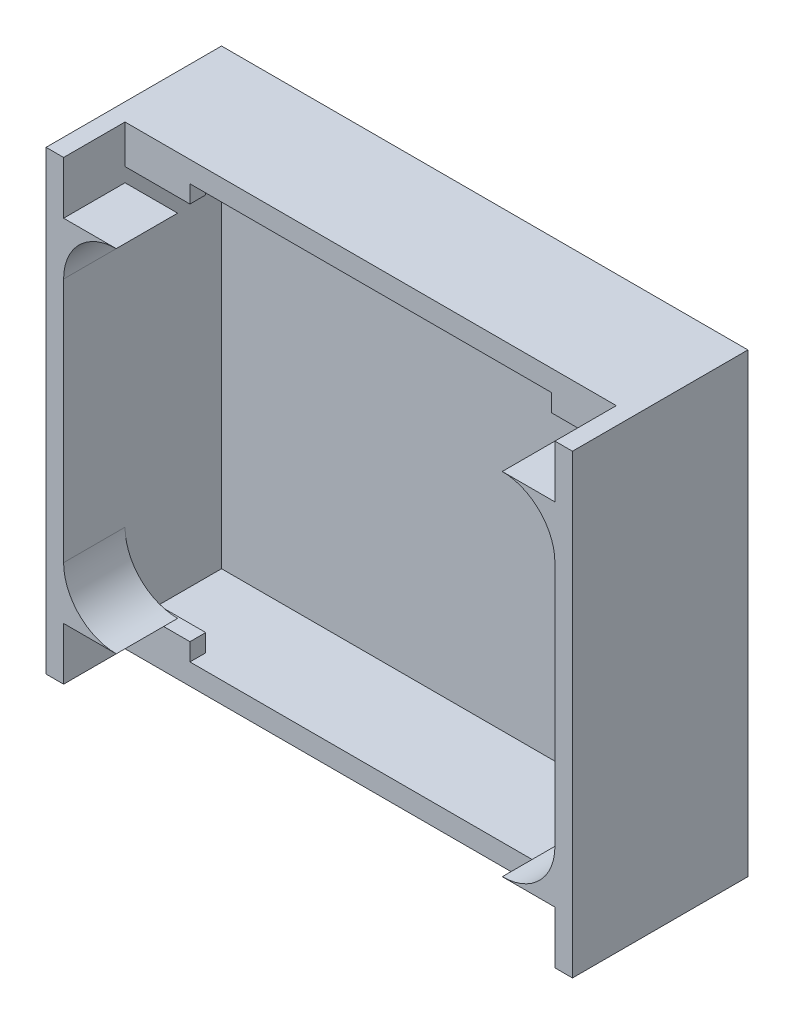
from build123d import *

# Parameters (mm, degrees)
SKETCH1_W           = 30
SKETCH1_H           = 26
BOSS_EXTRUDE1_DEPTH = 10
CUT_EXTRUDE2_DEPTH  = 3.5
SKETCH3_W           = 3
SKETCH3_H           = 3
CUT_EXTRUDE3_DEPTH  = 3.5
SKETCH4_W           = 28
SKETCH4_H           = 23.6
CUT_EXTRUDE4_DEPTH  = 5.5
SKETCH5_W           = 3.7
SKETCH5_H           = 0.9
BOSS_EXTRUDE2_DEPTH = 1
SKETCH6_W           = 3.7
SKETCH6_H           = 0.9
BOSS_EXTRUDE3_DEPTH = 1


with BuildPart() as part:
    # Sketch1 → Boss-Extrude1 (new body)
    with BuildSketch(Plane.XY):
        with Locations((0.224911006, 2.218978102)):
            Rectangle(SKETCH1_W, SKETCH1_H)
    extrude(amount=BOSS_EXTRUDE1_DEPTH)

    # Sketch2 → Cut-Extrude2 (cut)
    with BuildSketch(Plane.XY.offset(10)):
        with BuildLine():
            Line((-13.775088994, 9.218978102), (-13.775088994, -4.781021898))
            ThreePointArc((-13.775088994, -4.781021898), (-12.896409337, -6.902342241), (-10.775088994, -7.781021898))
            Line((-10.775088994, -7.781021898), (-10.775088994, -10.781021898))
            Line((-10.775088994, -10.781021898), (11.224911006, -10.781021898))
            Line((11.224911006, -10.781021898), (11.224911006, -7.781021898))
            ThreePointArc((11.224911006, -7.781021898), (13.34623135, -6.902342241), (14.224911006, -4.781021898))
            Line((14.224911006, -4.781021898), (14.224911006, 9.218978102))
            ThreePointArc((14.224911006, 9.218978102), (13.34623135, 11.340298446), (11.224911006, 12.218978102))
            Line((11.224911006, 12.218978102), (11.224911006, 15.218978102))
            Line((11.224911006, 15.218978102), (-10.775088994, 15.218978102))
            Line((-10.775088994, 15.218978102), (-10.775088994, 12.218978102))
            ThreePointArc((-10.775088994, 12.218978102), (-12.896409337, 11.340298446), (-13.775088994, 9.218978102))
        make_face()
    extrude(amount=-CUT_EXTRUDE2_DEPTH, mode=Mode.SUBTRACT)

    # Sketch3 → Cut-Extrude3 (cut)
    with BuildSketch(Plane.XY.offset(10)):
        with Locations((-12.275088994, 13.718978102)):
            Rectangle(SKETCH3_W, SKETCH3_H)
        with Locations((12.724911006, -9.281021898)):
            Rectangle(SKETCH3_W, SKETCH3_H)
        with Locations((-12.275088994, -9.281021898)):
            Rectangle(SKETCH3_W, SKETCH3_H)
        with Locations((12.724911006, 13.718978102)):
            Rectangle(SKETCH3_W, SKETCH3_H)
    extrude(amount=-CUT_EXTRUDE3_DEPTH, mode=Mode.SUBTRACT)

    # Sketch4 → Cut-Extrude4 (cut)
    with BuildSketch(Plane.XY.offset(6.5)):
        with Locations((0.224911006, 2.218978102)):
            Rectangle(SKETCH4_W, SKETCH4_H)
    extrude(amount=-CUT_EXTRUDE4_DEPTH, mode=Mode.SUBTRACT)

    # Sketch5 → Boss-Extrude2 (add)
    with BuildSketch(Plane(origin=(0, 14.018978102, 0), x_dir=(-1, 0, 0), z_dir=(0, -1, 0))):
        with Locations((11.925088994, -6.05)):
            Rectangle(SKETCH5_W, SKETCH5_H)
        with Locations((-12.374911006, -6.05)):
            Rectangle(SKETCH5_W, SKETCH5_H)
    extrude(amount=BOSS_EXTRUDE2_DEPTH)

    # Sketch6 → Boss-Extrude3 (add)
    with BuildSketch(Plane(origin=(0, -9.581021898, 0), x_dir=(1, 0, 0), z_dir=(0, 1, 0))):
        with Locations((12.374911006, -6.05)):
            Rectangle(SKETCH6_W, SKETCH6_H)
        with Locations((-11.925088994, -6.05)):
            Rectangle(SKETCH6_W, SKETCH6_H)
    extrude(amount=BOSS_EXTRUDE3_DEPTH)


solid = part.part
